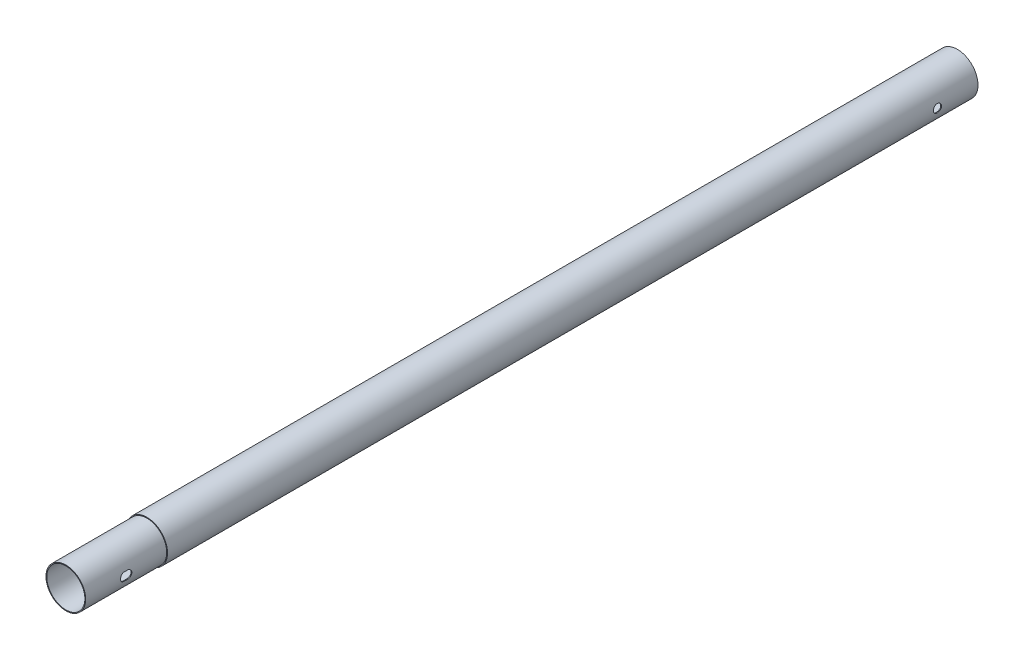
from build123d import *

# Parameters (mm, degrees)
SZKIC1_R                             = 25.5
SZKIC1_R_2                           = 24.5
DODANIE_WYCI_GNI_CIE1_DEPTH          = 1000
SZKIC3_R                             = 24.5
DODANIE_WYCI_GNI_CIE2_DEPTH          = 100
OTWORY_USTALAJ_CE_10_0MM2_AT_2_COUNT = 2
OTWORY_USTALAJ_CE_10_0MM2_AT_2_PITCH = 4
SZKIC15_R                            = 23.5
WYTNIJ_WYCI_GNI_CIE1_DEPTH           = 1101.0000001


with BuildPart() as part:
    # Szkic1 → Dodanie-wyciągnięcie1 (new body)
    with BuildSketch(Plane.XY):
        Circle(SZKIC1_R)
        Circle(SZKIC1_R_2, mode=Mode.SUBTRACT)
    extrude(amount=DODANIE_WYCI_GNI_CIE1_DEPTH)

    # Szkic9 → Otwory ustalające Ø10.0mm1 (revolve, cut)
    with BuildSketch(Plane(origin=(25.5, 0, 50), x_dir=(0, 0, -1), z_dir=(0, 1, 0))):
        Polygon((0, 0), (0, 51), (5, 51), (5, 0.025), (5.025, 0), align=None)
    revolve(axis=Axis((31.85, 0, 50), (-1, 0, 0)), mode=Mode.SUBTRACT)


with BuildPart() as body_2:
    # Szkic3 → Dodanie-wyciągnięcie2 (new body)
    with BuildSketch(Plane.XY.offset(1000)):
        Circle(SZKIC3_R)
    extrude(amount=DODANIE_WYCI_GNI_CIE2_DEPTH)

    # Szkic10 → Otwory ustalające Ø10.0mm2 (revolve, cut)
    with BuildSketch(Plane(origin=(24.5, 0, 1052), x_dir=(0, 0, -1), z_dir=(0, 1, 0))):
        Polygon((0, 0), (0, 50), (5, 50), (5, 0.025), (5.025, 0), align=None)
    otwory_ustalaj_ce_10_0mm2 = revolve(axis=Axis((30.85, 0, 1052), (-1, 0, 0)), mode=Mode.SUBTRACT)

    # Otwory ustalające Ø10.0mm2 at 2: Otwory ustalające Ø10.0mm2 ×2
    with Locations(*[(0, 0, -i * OTWORY_USTALAJ_CE_10_0MM2_AT_2_PITCH) for i in range(1, OTWORY_USTALAJ_CE_10_0MM2_AT_2_COUNT)]):
        add(otwory_ustalaj_ce_10_0mm2, mode=Mode.SUBTRACT)

    # Szkic12 → Otwory ustalające Ø10.0mm4 (revolve, cut)
    with BuildSketch(Plane(origin=(24.5, 0, 1050), x_dir=(0, 0, -1), z_dir=(0, 1, 0))):
        Polygon((0, 0), (0, 50), (5, 50), (5, 0.025), (5.025, 0), align=None)
    revolve(axis=Axis((30.85, 0, 1050), (-1, 0, 0)), mode=Mode.SUBTRACT)

    # Szkic13 → Otwory ustalające Ø10.0mm5 (revolve, cut)
    with BuildSketch(Plane(origin=(24.5, 0, 1051), x_dir=(0, 0, -1), z_dir=(0, 1, 0))):
        Polygon((0, 0), (0, 50), (5, 50), (5, 0.025), (5.025, 0), align=None)
    revolve(axis=Axis((30.85, 0, 1051), (-1, 0, 0)), mode=Mode.SUBTRACT)

    # Szkic14 → Otwory ustalające Ø10.0mm6 (revolve, cut)
    with BuildSketch(Plane(origin=(24.5, 0, 1049), x_dir=(0, 0, -1), z_dir=(0, 1, 0))):
        Polygon((0, 0), (0, 50), (5, 50), (5, 0.025), (5.025, 0), align=None)
    revolve(axis=Axis((30.85, 0, 1049), (-1, 0, 0)), mode=Mode.SUBTRACT)

    # Szkic15 → Wytnij-wyciągnięcie1 (cut, through all)
    with BuildSketch(Plane.XY.offset(1100)):
        Circle(SZKIC15_R)
    extrude(amount=-WYTNIJ_WYCI_GNI_CIE1_DEPTH, mode=Mode.SUBTRACT)


solid = Compound([part.part, body_2.part])
